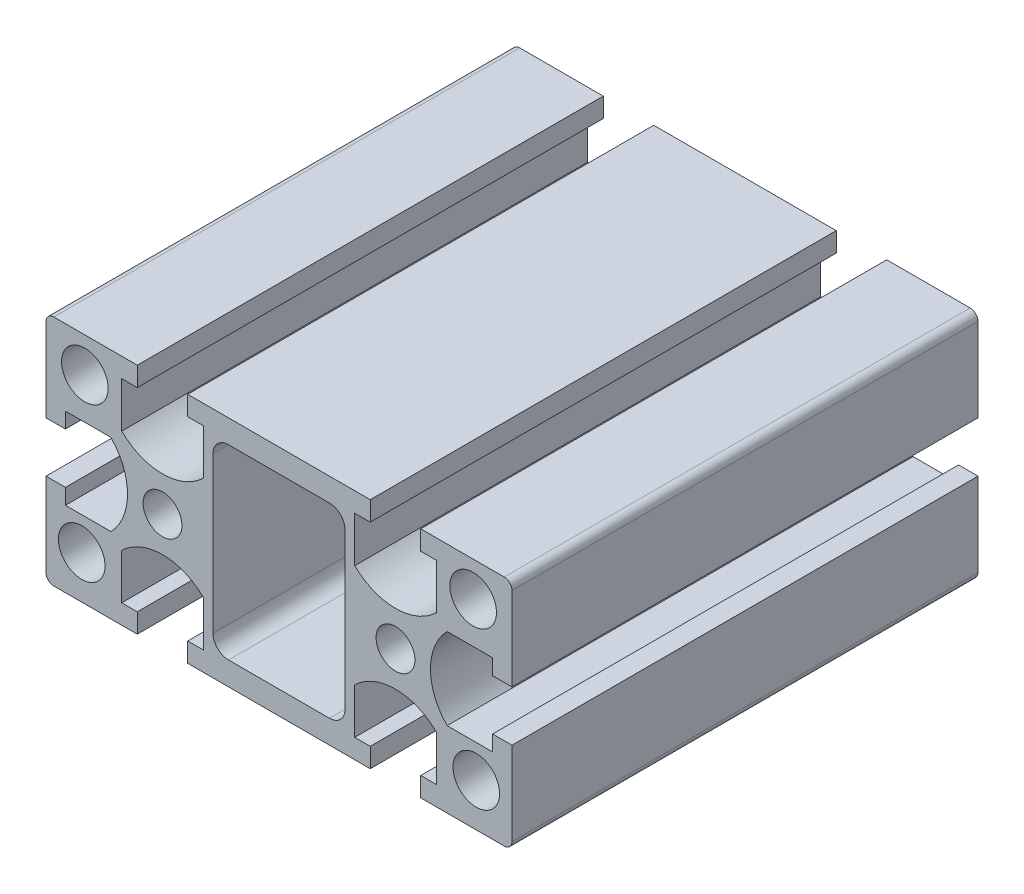
from build123d import *

# Parameters (mm, degrees)
MODEL_R             = 2.5
MODEL_R_2           = 3
BOSS_EXTRUDE1_DEPTH = 60


with BuildPart() as part:
    # Model → Boss-Extrude1 (new body)
    with BuildSketch(Plane.XY):
        with BuildLine():
            Line((-27.5, 3.25), (-30, 3.25))
            Line((-30, 3.25), (-30, 14))
            ThreePointArc((-30, 14), (-29.707106781, 14.707106781), (-29, 15))
            Line((-29, 15), (-18.25, 15))
            Line((-18.25, 15), (-18.25, 12.5))
            Line((-18.25, 12.5), (-20.25, 12.5))
            Line((-20.25, 12.5), (-20.25, 6.643928679))
            ThreePointArc((-20.25, 6.643928679), (-15, 4.5), (-9.75, 6.643928679))
            Line((-9.75, 6.643928679), (-9.75, 12.5))
            Line((-9.75, 12.5), (-11.75, 12.5))
            Line((-11.75, 12.5), (-11.75, 15))
            Line((-11.75, 15), (11.75, 15))
            Line((11.75, 15), (11.75, 12.5))
            Line((11.75, 12.5), (9.75, 12.5))
            Line((9.75, 12.5), (9.75, 6.643928679))
            ThreePointArc((9.75, 6.643928679), (15, 4.5), (20.25, 6.643928679))
            Line((20.25, 6.643928679), (20.25, 12.5))
            Line((20.25, 12.5), (18.25, 12.5))
            Line((18.25, 12.5), (18.25, 15))
            Line((18.25, 15), (29, 15))
            ThreePointArc((29, 15), (29.707106781, 14.707106781), (30, 14))
            Line((30, 14), (30, 3.25))
            Line((30, 3.25), (27.5, 3.25))
            Line((27.5, 3.25), (27.5, 5.25))
            Line((27.5, 5.25), (21.643928679, 5.25))
            ThreePointArc((21.643928679, 5.25), (19.5, 0), (21.643928679, -5.25))
            Line((21.643928679, -5.25), (27.5, -5.25))
            Line((27.5, -5.25), (27.5, -3.25))
            Line((27.5, -3.25), (30, -3.25))
            Line((30, -3.25), (30, -14))
            ThreePointArc((30, -14), (29.707106781, -14.707106781), (29, -15))
            Line((29, -15), (18.25, -15))
            Line((18.25, -15), (18.25, -12.5))
            Line((18.25, -12.5), (20.25, -12.5))
            Line((20.25, -12.5), (20.25, -6.643928679))
            ThreePointArc((20.25, -6.643928679), (15, -4.5), (9.75, -6.643928679))
            Line((9.75, -6.643928679), (9.75, -12.5))
            Line((9.75, -12.5), (11.75, -12.5))
            Line((11.75, -12.5), (11.75, -15))
            Line((11.75, -15), (-11.75, -15))
            Line((-11.75, -15), (-11.75, -12.5))
            Line((-11.75, -12.5), (-9.75, -12.5))
            Line((-9.75, -12.5), (-9.75, -6.643928679))
            ThreePointArc((-9.75, -6.643928679), (-15, -4.5), (-20.25, -6.643928679))
            Line((-20.25, -6.643928679), (-20.25, -12.5))
            Line((-20.25, -12.5), (-18.25, -12.5))
            Line((-18.25, -12.5), (-18.25, -15))
            Line((-18.25, -15), (-29, -15))
            ThreePointArc((-29, -15), (-29.707106781, -14.707106781), (-30, -14))
            Line((-30, -14), (-30, -3.25))
            Line((-30, -3.25), (-27.5, -3.25))
            Line((-27.5, -3.25), (-27.5, -5.25))
            Line((-27.5, -5.25), (-21.643928679, -5.25))
            ThreePointArc((-21.643928679, -5.25), (-19.5, 0), (-21.643928679, 5.25))
            Line((-21.643928679, 5.25), (-27.5, 5.25))
            Line((-27.5, 5.25), (-27.5, 3.25))
        make_face()
        with Locations((-15, 0)):
            Circle(MODEL_R, mode=Mode.SUBTRACT)
        with Locations((-25, 10.531430074)):
            Circle(MODEL_R_2, mode=Mode.SUBTRACT)
        with Locations((-25.399251578, -9.468569926)):
            Circle(MODEL_R_2, mode=Mode.SUBTRACT)
        with Locations((25.399251578, -9.468569926)):
            Circle(MODEL_R_2, mode=Mode.SUBTRACT)
        with Locations((15, 0)):
            Circle(MODEL_R, mode=Mode.SUBTRACT)
        with Locations((25, 10.531430074)):
            Circle(MODEL_R_2, mode=Mode.SUBTRACT)
        with BuildLine():
            Line((6.5, 12), (-6.5, 12))
            ThreePointArc((-6.5, 12), (-7.914213562, 11.414213562), (-8.5, 10))
            Line((-8.5, 10), (-8.5, -10))
            ThreePointArc((-8.5, -10), (-7.914213562, -11.414213562), (-6.5, -12))
            Line((-6.5, -12), (6.5, -12))
            ThreePointArc((6.5, -12), (7.914213562, -11.414213562), (8.5, -10))
            Line((8.5, -10), (8.5, 10))
            ThreePointArc((8.5, 10), (7.914213562, 11.414213562), (6.5, 12))
        make_face(mode=Mode.SUBTRACT)
    extrude(amount=BOSS_EXTRUDE1_DEPTH)


solid = part.part
